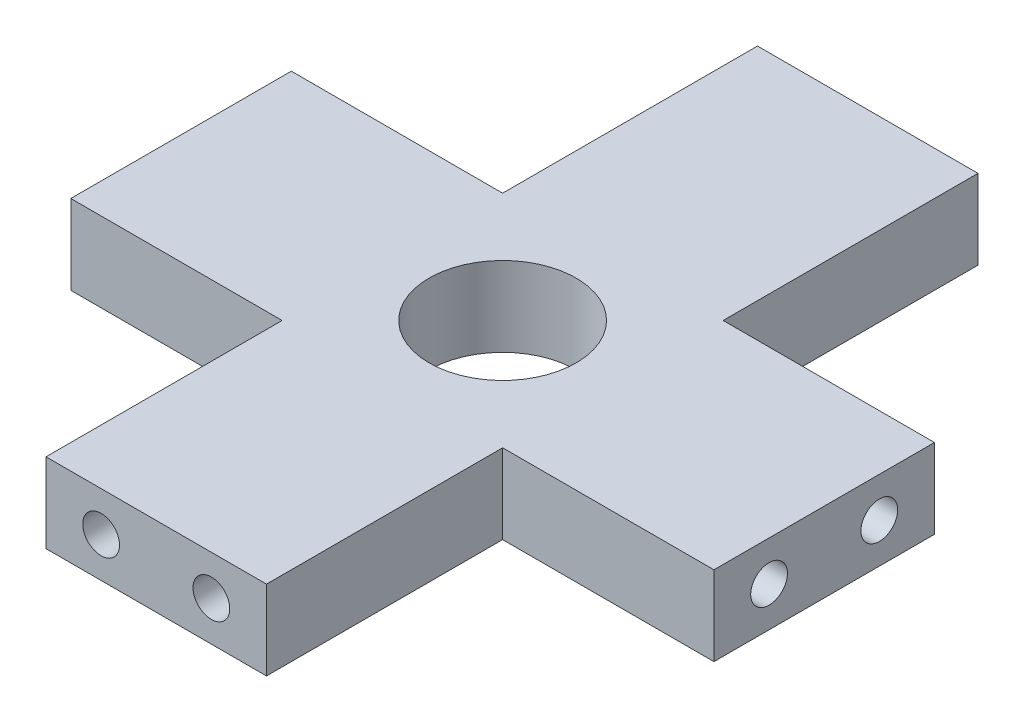
from build123d import *

# Parameters (mm, degrees)
SKETCH2_R           = 4
BOSS_EXTRUDE1_DEPTH = 4.33
SKETCH3_R           = 1
CUT_EXTRUDE1_DEPTH  = 5
SKETCH4_R           = 1
CUT_EXTRUDE2_DEPTH  = 5
SKETCH5_R           = 1
CUT_EXTRUDE3_DEPTH  = 5
SKETCH6_R           = 1
CUT_EXTRUDE4_DEPTH  = 5


with BuildPart() as part:
    # Sketch2 → Boss-Extrude1 (new body)
    with BuildSketch(Plane(origin=(0, 0, 0), x_dir=(1, 0, 0), z_dir=(0, 1, 0))):
        Polygon((0, 0), (12, 0), (12, 12.85), (23.5, 12.85), (23.5, 24.85), (12, 24.85), (12, 38.72), (0, 38.72), (0, 24.85), (-11.5, 24.85), (-11.5, 12.85), (0, 12.85), align=None)
        with Locations((6, 18.85)):
            Circle(SKETCH2_R, mode=Mode.SUBTRACT)
    extrude(amount=BOSS_EXTRUDE1_DEPTH)

    # Sketch3 → Cut-Extrude1 (cut)
    with BuildSketch(Plane.XY):
        with Locations((3, 2.165)):
            Circle(SKETCH3_R)
        with Locations((9, 2.165)):
            Circle(SKETCH3_R)
    extrude(amount=-CUT_EXTRUDE1_DEPTH, mode=Mode.SUBTRACT)

    # Sketch4 → Cut-Extrude2 (cut)
    with BuildSketch(Plane.ZY.offset(11.5)):
        with Locations((-21.85, 2.165)):
            Circle(SKETCH4_R)
        with Locations((-15.85, 2.165)):
            Circle(SKETCH4_R)
    extrude(amount=-CUT_EXTRUDE2_DEPTH, mode=Mode.SUBTRACT)

    # Sketch5 → Cut-Extrude3 (cut)
    with BuildSketch(Plane(origin=(0, 0, -38.72), x_dir=(-1, 0, 0), z_dir=(0, 0, -1))):
        with Locations((-9, 2.165)):
            Circle(SKETCH5_R)
        with Locations((-3, 2.165)):
            Circle(SKETCH5_R)
    extrude(amount=-CUT_EXTRUDE3_DEPTH, mode=Mode.SUBTRACT)

    # Sketch6 → Cut-Extrude4 (cut)
    with BuildSketch(Plane(origin=(23.5, 0, 0), x_dir=(0, 0, -1), z_dir=(1, 0, 0))):
        with Locations((15.85, 2.165)):
            Circle(SKETCH6_R)
        with Locations((21.85, 2.165)):
            Circle(SKETCH6_R)
    extrude(amount=-CUT_EXTRUDE4_DEPTH, mode=Mode.SUBTRACT)


solid = part.part
